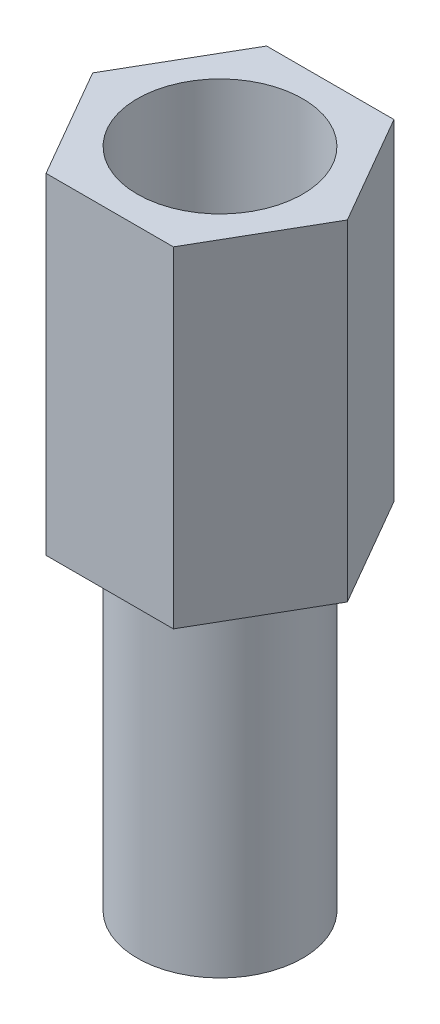
from build123d import *

# Parameters (mm, degrees)
SKETCH2_R           = 1.5
BOSS_EXTRUDE1_DEPTH = 6
SKETCH3_R           = 1.5
BOSS_EXTRUDE2_DEPTH = 6


with BuildPart() as part:
    # Sketch2 → Boss-Extrude1 (new body)
    with BuildSketch(Plane(origin=(0, 0, 0), x_dir=(1, 0, 0), z_dir=(0, 1, 0))):
        Polygon((1.154700538, 2), (-1.154700538, 2), (-2.309401077, 0), (-1.154700538, -2), (1.154700538, -2), (2.309401077, 0), align=None)
        Circle(SKETCH2_R, mode=Mode.SUBTRACT)
    extrude(amount=BOSS_EXTRUDE1_DEPTH)


with BuildPart() as body_2:
    # Sketch3 → Boss-Extrude2 (new body)
    with BuildSketch(Plane.XZ):
        Circle(SKETCH3_R)
    extrude(amount=BOSS_EXTRUDE2_DEPTH)


solid = Compound([part.part, body_2.part])
